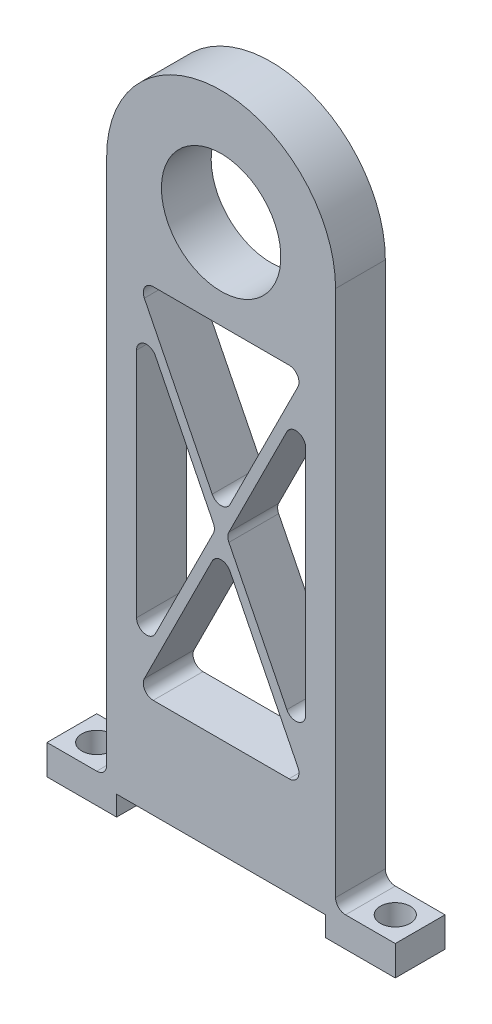
from build123d import *

# Parameters (mm, degrees)
SKETCH1_W           = 88.9
SKETCH1_H           = 12.7
SKETCH1_R           = 3.81
BOSS_EXTRUDE1_DEPTH = 7.62
SKETCH2_W           = 58.42
SKETCH2_H           = 12.7
BOSS_EXTRUDE2_DEPTH = 137.16
BOSS_EXTRUDE3_DEPTH = 12.7
SKETCH4_R           = 15.24
CUT_EXTRUDE1_DEPTH  = 12.7
CUT_EXTRUDE2_REACH  = 14.7
SKETCH5_W           = 53.34
SKETCH5_H           = 5.08
FILLET1_R           = 2.54
FILLET2_R           = 2.54


with BuildPart() as part:
    # Sketch1 → Boss-Extrude1 (new body)
    with BuildSketch(Plane(origin=(0, 0, 0), x_dir=(1, 0, 0), z_dir=(0, 1, 0))):
        Rectangle(SKETCH1_W, SKETCH1_H)
        with Locations((-38.1, 0)):
            Circle(SKETCH1_R, mode=Mode.SUBTRACT)
        with Locations((38.1, 0)):
            Circle(SKETCH1_R, mode=Mode.SUBTRACT)
    extrude(amount=BOSS_EXTRUDE1_DEPTH)

    # Sketch2 → Boss-Extrude2 (add)
    with BuildSketch(Plane(origin=(0, 7.62, 0), x_dir=(1, 0, 0), z_dir=(0, 1, 0))):
        Rectangle(SKETCH2_W, SKETCH2_H)
    extrude(amount=BOSS_EXTRUDE2_DEPTH)

    # Sketch3 → Boss-Extrude3 (add)
    with BuildSketch(Plane.XY.offset(6.35)):
        with BuildLine():
            Line((29.21, 144.78), (-29.21, 144.78))
            ThreePointArc((-29.21, 144.78), (0, 173.99), (29.21, 144.78))
        make_face()
    extrude(amount=-BOSS_EXTRUDE3_DEPTH)

    # Sketch4 → Cut-Extrude1 (cut)
    with BuildSketch(Plane(origin=(0, 0, -6.35), x_dir=(-1, 0, 0), z_dir=(0, 0, -1))):
        with Locations((0, 144.78)):
            Circle(SKETCH4_R)
    extrude(amount=-CUT_EXTRUDE1_DEPTH, mode=Mode.SUBTRACT)

    # Sketch5 → Cut-Extrude2 (cut, up to next)
    with BuildSketch(Plane.XY.offset(6.35), mode=Mode.PRIVATE) as cut_extrude2_sk1:
        Polygon((-21.440096834, 121.92), (21.440096834, 121.92), (0, 79.039806331), align=None)
    cut_extrude2_tool1 = extrude(cut_extrude2_sk1.sketch, amount=-CUT_EXTRUDE2_REACH, mode=Mode.PRIVATE) & part.part
    add(cut_extrude2_tool1.solids().sort_by_distance((0, 107.626602, 6.35))[0], mode=Mode.SUBTRACT)
    # Sketch5 → Cut-Extrude2 (cut, up to next)
    with BuildSketch(Plane.XY.offset(6.35), mode=Mode.PRIVATE) as cut_extrude2_sk2:
        Polygon((-21.59, 116.540193669), (-1.419903166, 76.2), (-21.59, 35.859806331), align=None)
    cut_extrude2_tool2 = extrude(cut_extrude2_sk2.sketch, amount=-CUT_EXTRUDE2_REACH, mode=Mode.PRIVATE) & part.part
    add(cut_extrude2_tool2.solids().sort_by_distance((-14.866634, 76.2, 6.35))[0], mode=Mode.SUBTRACT)
    # Sketch5 → Cut-Extrude2 (cut, up to next)
    with BuildSketch(Plane.XY.offset(6.35), mode=Mode.PRIVATE) as cut_extrude2_sk3:
        Polygon((0, 73.360193669), (-21.440096834, 30.48), (21.440096834, 30.48), align=None)
    cut_extrude2_tool3 = extrude(cut_extrude2_sk3.sketch, amount=-CUT_EXTRUDE2_REACH, mode=Mode.PRIVATE) & part.part
    add(cut_extrude2_tool3.solids().sort_by_distance((0, 44.773398, 6.35))[0], mode=Mode.SUBTRACT)
    # Sketch5 → Cut-Extrude2 (cut, up to next)
    with BuildSketch(Plane.XY.offset(6.35), mode=Mode.PRIVATE) as cut_extrude2_sk4:
        Polygon((21.59, 116.540193669), (21.59, 35.859806331), (1.419903166, 76.2), align=None)
    cut_extrude2_tool4 = extrude(cut_extrude2_sk4.sketch, amount=-CUT_EXTRUDE2_REACH, mode=Mode.PRIVATE) & part.part
    add(cut_extrude2_tool4.solids().sort_by_distance((14.866634, 76.2, 6.35))[0], mode=Mode.SUBTRACT)
    # Sketch5 → Cut-Extrude2 (cut, up to next)
    with BuildSketch(Plane.XY.offset(6.35), mode=Mode.PRIVATE) as cut_extrude2_sk5:
        with Locations((0, 2.54)):
            Rectangle(SKETCH5_W, SKETCH5_H)
    cut_extrude2_tool5 = extrude(cut_extrude2_sk5.sketch, amount=-CUT_EXTRUDE2_REACH, mode=Mode.PRIVATE) & part.part
    add(cut_extrude2_tool5.solids().sort_by_distance((0, 2.54, 6.35))[0], mode=Mode.SUBTRACT)

    # Fillet1
    fillet1_edges = [part.edges().sort_by_distance(p)[0] for p in [
        (-29.21, 7.62, 0),
        (29.21, 7.62, 0),
    ]]
    fillet(fillet1_edges, radius=FILLET1_R)

    # Fillet2
    fillet2_edges = [part.edges().sort_by_distance(p)[0] for p in [
        (0, 73.360193669, 0),
        (21.440096834, 30.48, 0),
        (-21.440096834, 30.48, 0),
        (21.59, 35.859806331, 0),
        (1.419903166, 76.2, 0),
        (21.59, 116.540193669, 0),
        (-21.59, 35.859806331, 0),
        (-21.59, 116.540193669, 0),
        (-1.419903166, 76.2, 0),
        (21.440096834, 121.92, 0),
        (0, 79.039806331, 0),
        (-21.440096834, 121.92, 0),
    ]]
    fillet(fillet2_edges, radius=FILLET2_R)


solid = part.part
